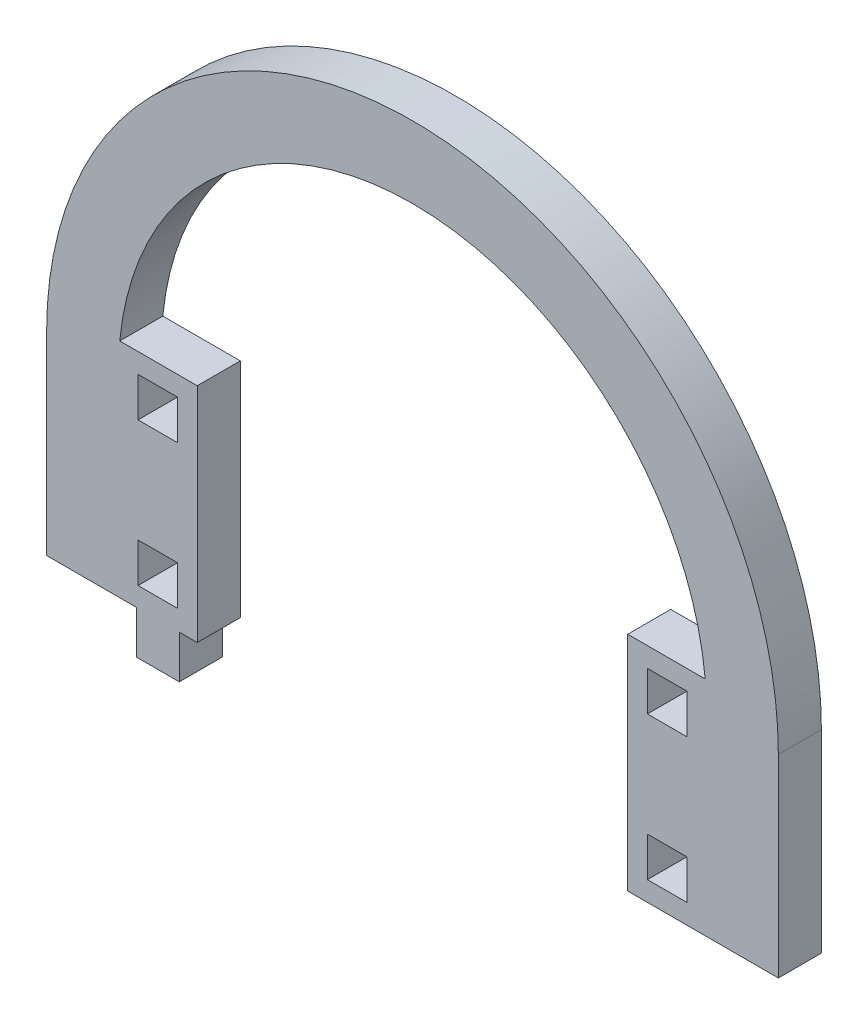
from build123d import *

# Parameters (mm, degrees)
MODEL_W             = 5.5
MODEL_H             = 5.5
BOSS_EXTRUDE1_DEPTH = 6


with BuildPart() as part:
    # Model → Boss-Extrude1 (new body)
    with BuildSketch(Plane.XY):
        with BuildLine():
            Line((3179.498666669, 1276.781770146), (3179.498666669, 1249.781770146))
            Line((3179.498666669, 1249.781770146), (3191.998666669, 1249.781770146))
            Line((3191.998666669, 1249.781770146), (3191.998666669, 1243.781770146))
            Line((3191.998666669, 1243.781770146), (3197.998666669, 1243.781770146))
            Line((3197.998666669, 1243.781770146), (3197.998666669, 1249.781770146))
            Line((3197.998666669, 1249.781770146), (3200.498666669, 1249.781770146))
            Line((3200.498666669, 1249.781770146), (3200.498666669, 1280.781770146))
            Line((3200.498666669, 1280.781770146), (3189.694255143, 1280.781770146))
            ThreePointArc((3189.694255143, 1280.781770146), (3230.498666669, 1317.781770146), (3271.303078196, 1280.781770146))
            Line((3271.303078196, 1280.781770146), (3260.498666669, 1280.781770146))
            Line((3260.498666669, 1280.781770146), (3260.498666669, 1249.781770146))
            Line((3260.498666669, 1249.781770146), (3271.498666669, 1249.781770146))
            Line((3271.498666669, 1249.781770146), (3281.498666669, 1249.781770146))
            Line((3281.498666669, 1249.781770146), (3281.498666669, 1276.781770146))
            ThreePointArc((3281.498666669, 1276.781770146), (3230.498666669, 1327.781770146), (3179.498666669, 1276.781770146))
        make_face()
        with Locations((3265.998666669, 1255.281770146)):
            Rectangle(MODEL_W, MODEL_H, mode=Mode.SUBTRACT)
        with Locations((3265.998666669, 1275.281770146)):
            Rectangle(MODEL_W, MODEL_H, mode=Mode.SUBTRACT)
        with Locations((3194.998666669, 1255.281770146)):
            Rectangle(MODEL_W, MODEL_H, mode=Mode.SUBTRACT)
        with Locations((3194.998666669, 1275.281770146)):
            Rectangle(MODEL_W, MODEL_H, mode=Mode.SUBTRACT)
    extrude(amount=BOSS_EXTRUDE1_DEPTH)


solid = part.part
